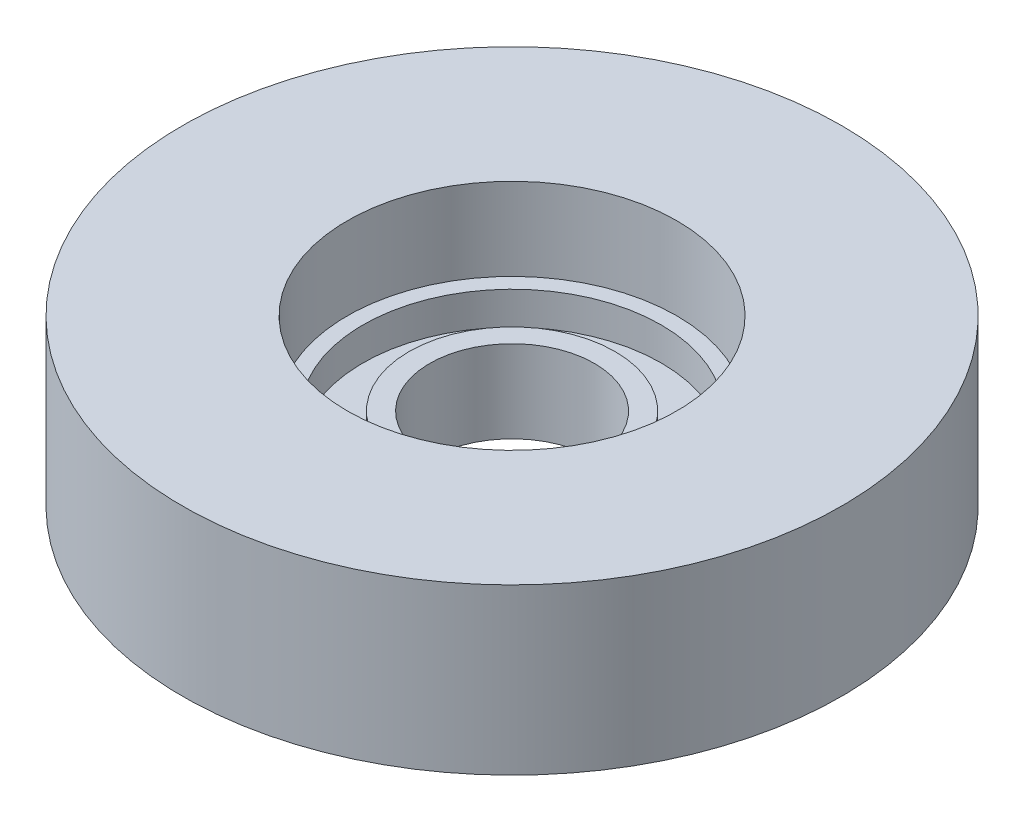
from build123d import *


with BuildPart() as part:
    # Sketch1 → Revolve1 (revolve)
    with BuildSketch(Plane.XY):
        Polygon((-6.35, 0), (-6.35, 6.35), (-7.9375, 6.35), (-7.9375, 3.81), (-11.4935, 3.81), (-11.4935, 6.35), (-12.7, 6.35), (-12.7, 12.7), (-25.4, 12.7), (-25.4, 0), (-23.8125, 0), (-23.8125, 2.54), (-20.2565, 2.54), (-20.2565, 0), align=None)
    revolve(axis=Axis((0, 0, 0), (0, 1, 0)))


solid = part.part
